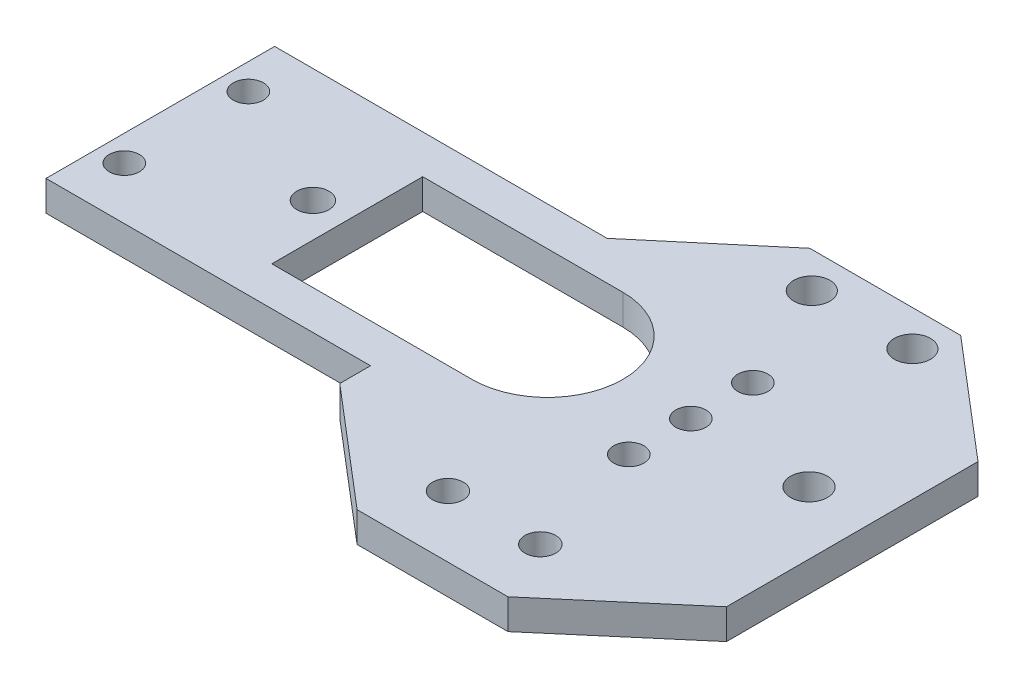
from build123d import *

# Parameters (mm, degrees)
CROQUIS1_R              = 1.53
CROQUIS1_R_2            = 1.837919526
CROQUIS1_R_3            = 1.597275243
CROQUIS1_R_4            = 1.5
SALIENTE_EXTRUIR1_DEPTH = 3
CROQUIS2_R              = 1.8
CORTAR_EXTRUIR1_DEPTH   = 10


with BuildPart() as part:
    # Croquis1 → Saliente-Extruir1 (new body)
    with BuildSketch(Plane(origin=(0, 0, 0), x_dir=(1, 0, 0), z_dir=(0, 1, 0))):
        Polygon((-26.514888395, -10.582637626), (-26.514888395, -7.527182045), (-40.886979894, -7.527182045), (-58.77250276, -7.527182045), (-58.77250276, 15.200062733), (-41.405808266, 15.200062733), (-25.724953766, 15.200062733), (-14.794888395, 24.417362374), (0.205111605, 24.417362374), (11.925111605, 14.417362374), (11.925111605, -10.582637626), (0.205111605, -20.582637626), (-14.794888395, -20.582637626), align=None)
        with Locations((-11.884888395, -14.457637626)):
            Circle(CROQUIS1_R, mode=Mode.SUBTRACT)
        with Locations((-2.704888395, -14.457637626)):
            Circle(CROQUIS1_R, mode=Mode.SUBTRACT)
        with Locations((5.705111605, 3.842362374)):
            Circle(CROQUIS1_R_2, mode=Mode.SUBTRACT)
        with Locations((-43.610544187, 3.842362374)):
            Circle(CROQUIS1_R_3, mode=Mode.SUBTRACT)
        with Locations((-6.044888395, 3.842362374)):
            Circle(CROQUIS1_R_4, mode=Mode.SUBTRACT)
        with Locations((-6.044888395, 10.008584025)):
            Circle(CROQUIS1_R_4, mode=Mode.SUBTRACT)
        with Locations((-6.044888395, -2.323859276)):
            Circle(CROQUIS1_R_4, mode=Mode.SUBTRACT)
        with Locations((-56.194888395, 10.008584025)):
            Circle(CROQUIS1_R_4, mode=Mode.SUBTRACT)
        with Locations((-56.194888395, -2.323859276)):
            Circle(CROQUIS1_R_4, mode=Mode.SUBTRACT)
        with BuildLine():
            Line((-40.195554385, 11.342362374), (-20.294888395, 11.342362374))
            ThreePointArc((-20.294888395, 11.342362374), (-12.794888395, 3.842362374), (-20.294888395, -3.657637626))
            Line((-20.294888395, -3.657637626), (-40.195554385, -3.657637626))
            Line((-40.195554385, -3.657637626), (-40.195554385, 11.342362374))
        make_face(mode=Mode.SUBTRACT)
    extrude(amount=SALIENTE_EXTRUIR1_DEPTH)

    # Croquis2 → Cortar-Extruir1 (cut)
    with BuildSketch(Plane(origin=(0, 3, 0), x_dir=(1, 0, 0), z_dir=(0, 1, 0))):
        with Locations((-11.039224955, 20.862391136)):
            Circle(CROQUIS2_R)
        with Locations((-1.039224955, 20.862391136)):
            Circle(CROQUIS2_R)
    extrude(amount=-CORTAR_EXTRUIR1_DEPTH, mode=Mode.SUBTRACT)


solid = part.part
